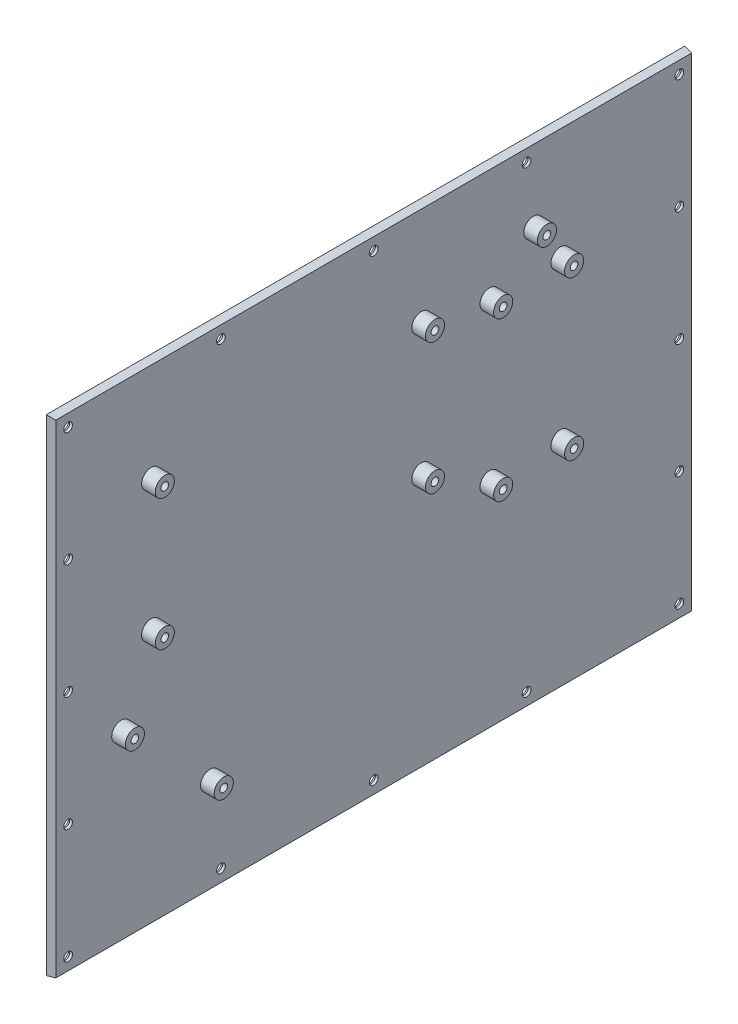
from build123d import *

# Parameters (mm, degrees)
SKETCH1_W           = 234
SKETCH1_H           = 178
BOSS_EXTRUDE1_DEPTH = 3
BOSS_EXTRUDE1_TAPER = 9
SKETCH2_R           = 3.5
SKETCH2_R_2         = 1.4
BOSS_EXTRUDE2_DEPTH = 5
SKETCH3_R           = 1.6
CUT_EXTRUDE1_DEPTH  = 3
CHAMFER1_SIZE       = 2


with BuildPart() as part:
    # Sketch1 → Boss-Extrude1 (new body)
    with BuildSketch(Plane(origin=(0, 0, 0), x_dir=(0, 0, -1), z_dir=(1, 0, 0))):
        Rectangle(SKETCH1_W, SKETCH1_H)
    extrude(amount=BOSS_EXTRUDE1_DEPTH, taper=BOSS_EXTRUDE1_TAPER)

    # Sketch2 → Boss-Extrude2 (add)
    with BuildSketch(Plane(origin=(3, 0, 0), x_dir=(0, 0, -1), z_dir=(1, 0, 0))):
        with Locations((-92.524846679, -22.175153321)):
            Circle(SKETCH2_R)
        with Locations((-92.524846679, -22.175153321)):
            Circle(SKETCH2_R_2, mode=Mode.SUBTRACT)
        with Locations((58.475153321, 62.224846679)):
            Circle(SKETCH2_R)
        with Locations((58.475153321, 62.224846679)):
            Circle(SKETCH2_R_2, mode=Mode.SUBTRACT)
        with Locations((-81.563741741, 52.524846679)):
            Circle(SKETCH2_R)
        with Locations((-81.563741741, 52.524846679)):
            Circle(SKETCH2_R_2, mode=Mode.SUBTRACT)
        with Locations((17.436258259, 52.524846679)):
            Circle(SKETCH2_R)
        with Locations((17.436258259, 52.524846679)):
            Circle(SKETCH2_R_2, mode=Mode.SUBTRACT)
        with Locations((42.436258259, 47.531127093)):
            Circle(SKETCH2_R)
        with Locations((42.436258259, 47.531127093)):
            Circle(SKETCH2_R_2, mode=Mode.SUBTRACT)
        with Locations((68.436258259, 47.531127093)):
            Circle(SKETCH2_R)
        with Locations((68.436258259, 47.531127093)):
            Circle(SKETCH2_R_2, mode=Mode.SUBTRACT)
        with Locations((42.436258259, -10.468872907)):
            Circle(SKETCH2_R)
        with Locations((42.436258259, -10.468872907)):
            Circle(SKETCH2_R_2, mode=Mode.SUBTRACT)
        with Locations((68.436258259, -10.468872907)):
            Circle(SKETCH2_R)
        with Locations((68.436258259, -10.468872907)):
            Circle(SKETCH2_R_2, mode=Mode.SUBTRACT)
        with Locations((17.436258259, 4.524846679)):
            Circle(SKETCH2_R)
        with Locations((17.436258259, 4.524846679)):
            Circle(SKETCH2_R_2, mode=Mode.SUBTRACT)
        with Locations((-81.563741741, 4.524846679)):
            Circle(SKETCH2_R)
        with Locations((-81.563741741, 4.524846679)):
            Circle(SKETCH2_R_2, mode=Mode.SUBTRACT)
        with Locations((-59.964914916, -54)):
            Circle(SKETCH2_R)
        with Locations((-59.964914916, -54)):
            Circle(SKETCH2_R_2, mode=Mode.SUBTRACT)
    extrude(amount=BOSS_EXTRUDE2_DEPTH)

    # Sketch3 → Cut-Extrude1 (cut)
    with BuildSketch(Plane.ZY):
        with Locations((-112, 84)):
            Circle(SKETCH3_R)
        with Locations((-56, 84)):
            Circle(SKETCH3_R)
        with Locations((0, 84)):
            Circle(SKETCH3_R)
        with Locations((56, 84)):
            Circle(SKETCH3_R)
        with Locations((112, 84)):
            Circle(SKETCH3_R)
        with Locations((112, 42)):
            Circle(SKETCH3_R)
        with Locations((112, 0)):
            Circle(SKETCH3_R)
        with Locations((112, -42)):
            Circle(SKETCH3_R)
        with Locations((112, -84)):
            Circle(SKETCH3_R)
        with Locations((56, -84)):
            Circle(SKETCH3_R)
        with Locations((0, -84)):
            Circle(SKETCH3_R)
        with Locations((-56, -84)):
            Circle(SKETCH3_R)
        with Locations((-112, -84)):
            Circle(SKETCH3_R)
        with Locations((-112, 42)):
            Circle(SKETCH3_R)
        with Locations((-112, 0)):
            Circle(SKETCH3_R)
        with Locations((-112, -42)):
            Circle(SKETCH3_R)
    extrude(amount=-CUT_EXTRUDE1_DEPTH, mode=Mode.SUBTRACT)

    # Chamfer1
    chamfer1_edges = [part.edges().sort_by_distance(p)[0] for p in [
        (0, 84, 54.4),
        (0, 84, -1.6),
        (0, 84, -57.6),
        (0, 84, 110.4),
        (0, -42, 110.4),
        (0, 0, 110.4),
        (0, 42, 110.4),
        (0, -84, 110.4),
        (0, -84, 54.4),
        (0, -84, -1.6),
        (0, -84, -57.6),
        (0, -84, -113.6),
        (0, 42, -113.6),
        (0, 0, -113.6),
        (0, -42, -113.6),
        (0, 84, -113.6),
    ]]
    chamfer(chamfer1_edges, length=CHAMFER1_SIZE)


solid = part.part
